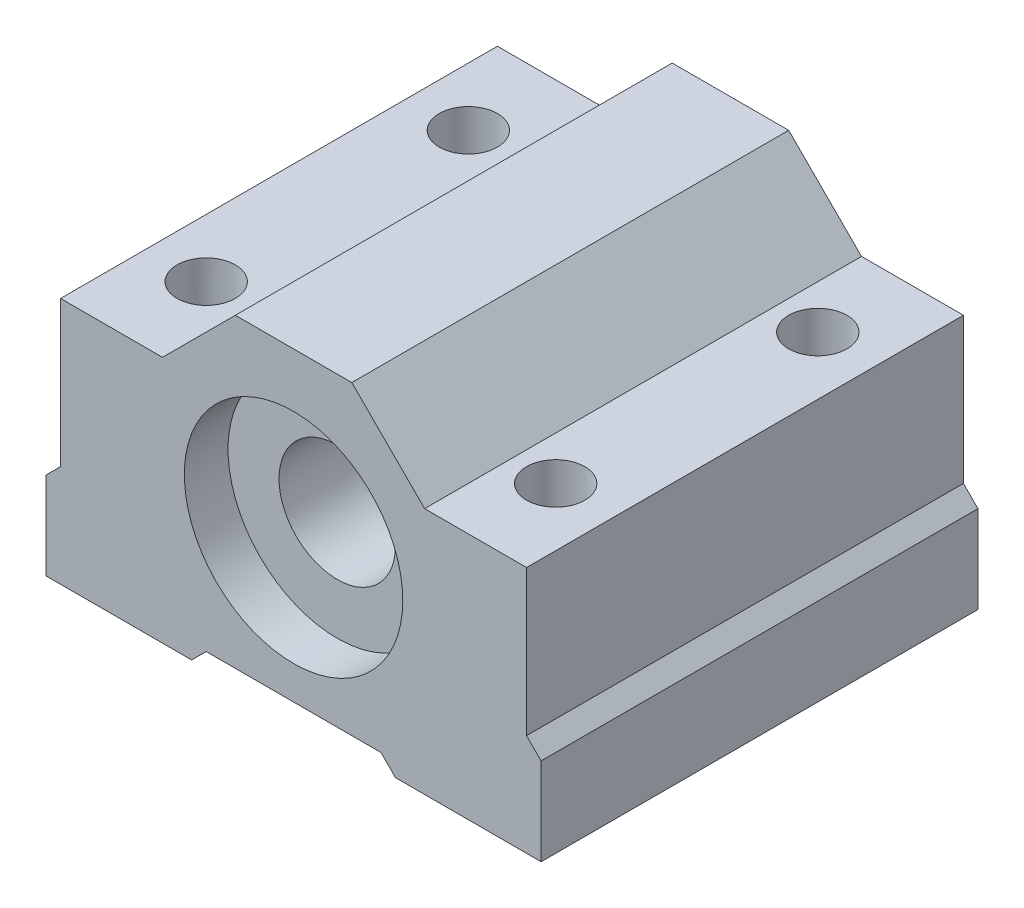
from build123d import *

# Parameters (mm, degrees)
BOSS_EXTRUDE1_DEPTH      = 15
BOSS_EXTRUDE1_DEPTH_BACK = 15
CUT_EXTRUDE1_START       = -12
SKETCH2_R                = 7.5
CUT_EXTRUDE1_DEPTH       = 14.293178723
SKETCH3_R                = 4
CUT_EXTRUDE2_DEPTH       = 34.819297596
SKETCH4_R                = 2
CUT_EXTRUDE3_DEPTH       = 32.591137998


with BuildPart() as part:
    # Sketch1 → Boss-Extrude1 (new, two sides: drawn at the far end of the back side and taken through both)
    with BuildSketch(Plane.XY.offset(-BOSS_EXTRUDE1_DEPTH_BACK)):
        Polygon((7, -10.786397104), (17, -10.786397104), (17, -4.786397104), (16, -3.786397104), (16, 6.213602896), (9, 6.213602896), (4, 11.213602896), (-4, 11.213602896), (-9, 6.213602896), (-16, 6.213602896), (-16, -3.786397104), (-17, -4.786397104), (-17, -10.786397104), (-7, -10.786397104), (-6, -9.786397104), (6, -9.786397104), align=None)
    extrude(amount=BOSS_EXTRUDE1_DEPTH + BOSS_EXTRUDE1_DEPTH_BACK)

    # Sketch2 → Cut-Extrude1 (cut, through all)
    with BuildSketch(Plane.XY.offset(CUT_EXTRUDE1_START)):
        Circle(SKETCH2_R)
    cut_extrude1 = extrude(amount=-CUT_EXTRUDE1_DEPTH, mode=Mode.SUBTRACT)

    # Mirror1: Cut-Extrude1 across plane
    add(cut_extrude1.mirror(Plane.XY), mode=Mode.SUBTRACT)

    # Sketch3 → Cut-Extrude2 (cut, through all)
    with BuildSketch(Plane.XY.offset(12)):
        Circle(SKETCH3_R)
    extrude(amount=-CUT_EXTRUDE2_DEPTH, mode=Mode.SUBTRACT)

    # Sketch4 → Cut-Extrude3 (cut, through all)
    with BuildSketch(Plane.XZ.offset(10.786397104)):
        with Locations((12, 9)):
            Circle(SKETCH4_R)
        with Locations((-12, 9)):
            Circle(SKETCH4_R)
        with Locations((12, -9)):
            Circle(SKETCH4_R)
        with Locations((-12, -9)):
            Circle(SKETCH4_R)
    extrude(amount=-CUT_EXTRUDE3_DEPTH, mode=Mode.SUBTRACT)


solid = part.part
